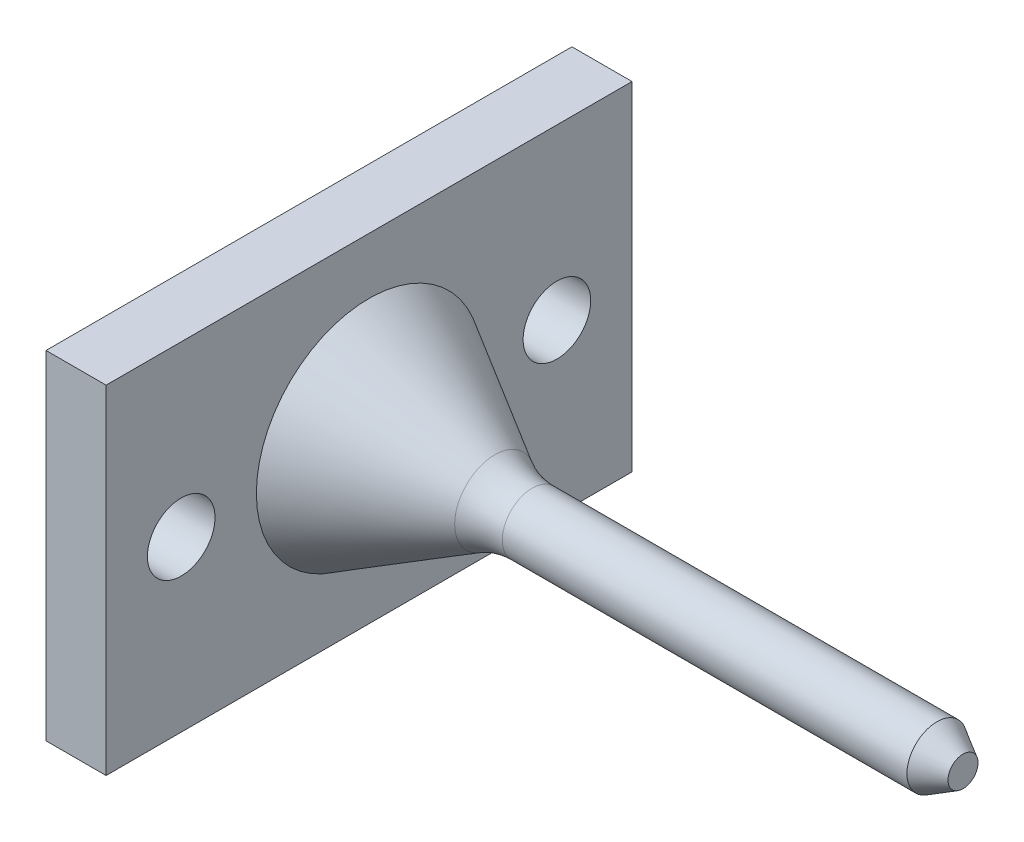
from build123d import *

# Parameters (mm, degrees)
FASE1_SIZE                      = 2
FASE1_SIZE2                     = 3.464101615
SKIZZE2_W                       = 70
SKIZZE2_H                       = 45
SKIZZE2_R                       = 4.5
AUFSATZ_LINEAR_AUSTRAGEN1_DEPTH = 8


with BuildPart() as part:
    # Skizze1 → Rotation1 (revolve)
    with BuildSketch(Plane.XY):
        with BuildLine():
            Line((79.052558883, 0), (79.052558883, 4))
            Line((79.052558883, 4), (21.732050808, 4))
            ThreePointArc((21.732050808, 4), (19.143860357, 4.340741737), (16.732050808, 5.339745962))
            Line((16.732050808, 5.339745962), (0, 15))
            Line((0, 15), (0, 0))
            Line((0, 0), (79.052558883, 0))
        make_face()
    revolve(axis=Axis((0, 0, 0), (1, 0, 0)))

    # Fase1
    fase1_edges = [part.edges().sort_by_distance(p)[0] for p in [
        (79.052558883, -4, 0),
    ]]
    fase1_side = [part.faces().sort_by_distance(p)[0] for p in [
        (79.052558883, 0, 0),
    ]]
    chamfer(fase1_edges, length=FASE1_SIZE, length2=FASE1_SIZE2, reference=fase1_side[0])

    # Skizze2 → Aufsatz-Linear austragen1 (add)
    with BuildSketch(Plane.ZY):
        Rectangle(SKIZZE2_W, SKIZZE2_H)
        with Locations((-25, 0)):
            Circle(SKIZZE2_R, mode=Mode.SUBTRACT)
        with Locations((25, 0)):
            Circle(SKIZZE2_R, mode=Mode.SUBTRACT)
    extrude(amount=AUFSATZ_LINEAR_AUSTRAGEN1_DEPTH)


solid = part.part
